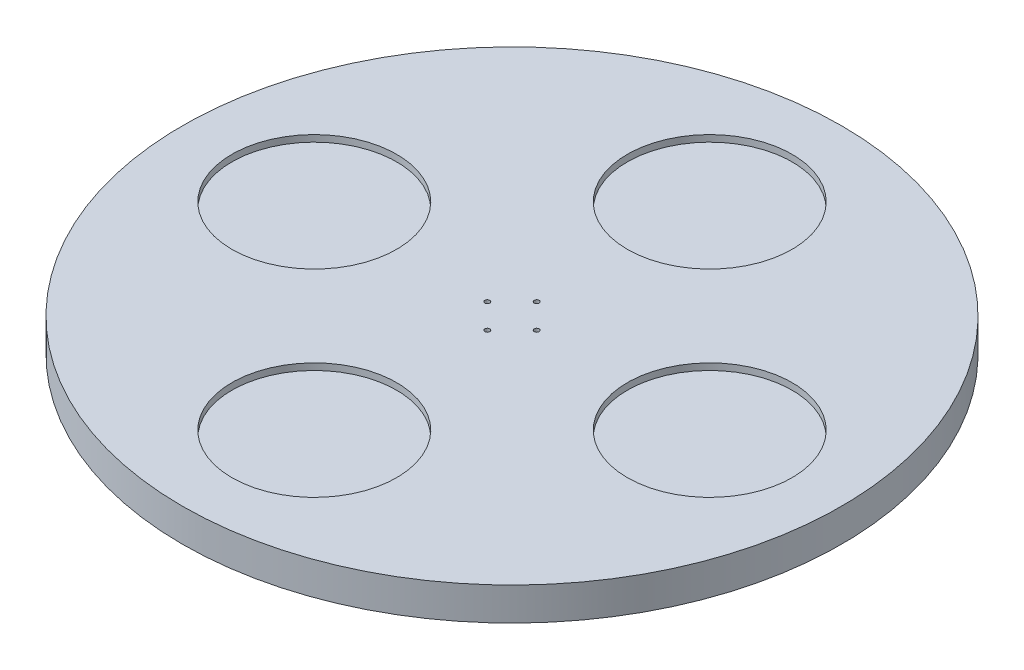
from build123d import *

# Parameters (mm, degrees)
CROQUIS1_R              = 100
SALIENTE_EXTRUIR1_DEPTH = 10
CROQUIS2_R              = 0.75
CORTAR_EXTRUIR1_DEPTH   = 11
CROQUIS3_R              = 25
CORTAR_EXTRUIR2_DEPTH   = 2


with BuildPart() as part:
    # Croquis1 → Saliente-Extruir1 (new body)
    with BuildSketch(Plane(origin=(0, 0, 0), x_dir=(1, 0, 0), z_dir=(0, 1, 0))):
        Circle(CROQUIS1_R)
    extrude(amount=SALIENTE_EXTRUIR1_DEPTH)

    # Croquis2 → Cortar-Extruir1 (cut, through all)
    with BuildSketch(Plane(origin=(0, 10, 0), x_dir=(1, 0, 0), z_dir=(0, 1, 0))):
        with Locations((-7.5, 0)):
            Circle(CROQUIS2_R)
        with Locations((0, -7.5)):
            Circle(CROQUIS2_R)
        with Locations((7.5, 0)):
            Circle(CROQUIS2_R)
        with Locations((0, 7.5)):
            Circle(CROQUIS2_R)
    extrude(amount=-CORTAR_EXTRUIR1_DEPTH, mode=Mode.SUBTRACT)

    # Croquis3 → Cortar-Extruir2 (cut)
    with BuildSketch(Plane(origin=(0, 10, 0), x_dir=(1, 0, 0), z_dir=(0, 1, 0))):
        with Locations((-60, 0)):
            Circle(CROQUIS3_R)
        with Locations((0, 60)):
            Circle(CROQUIS3_R)
        with Locations((60, 0)):
            Circle(CROQUIS3_R)
        with Locations((0, -60)):
            Circle(CROQUIS3_R)
    extrude(amount=-CORTAR_EXTRUIR2_DEPTH, mode=Mode.SUBTRACT)


solid = part.part
